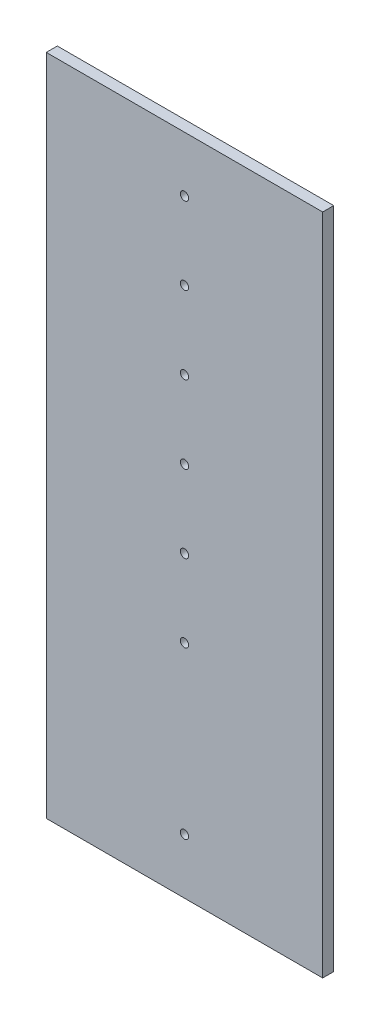
from build123d import *

# Parameters (mm, degrees)
SKETCH1_W           = 50
SKETCH1_H           = 120
BOSS_EXTRUDE2_DEPTH = 2
SKETCH2_R           = 0.75
CUT_EXTRUDE2_DEPTH  = 2


with BuildPart() as part:
    # Sketch1 → Boss-Extrude2 (new body)
    with BuildSketch(Plane.XY):
        with Locations((25, 60)):
            Rectangle(SKETCH1_W, SKETCH1_H)
    extrude(amount=BOSS_EXTRUDE2_DEPTH)

    # Sketch2 → Cut-Extrude2 (cut)
    with BuildSketch(Plane.XY):
        with Locations((25, 110)):
            Circle(SKETCH2_R)
        with Locations((25, 96)):
            Circle(SKETCH2_R)
        with Locations((25, 82)):
            Circle(SKETCH2_R)
        with Locations((25, 68)):
            Circle(SKETCH2_R)
        with Locations((25, 54)):
            Circle(SKETCH2_R)
        with Locations((25, 40)):
            Circle(SKETCH2_R)
        with Locations((25, 10)):
            Circle(SKETCH2_R)
    extrude(amount=CUT_EXTRUDE2_DEPTH, mode=Mode.SUBTRACT)


solid = part.part
